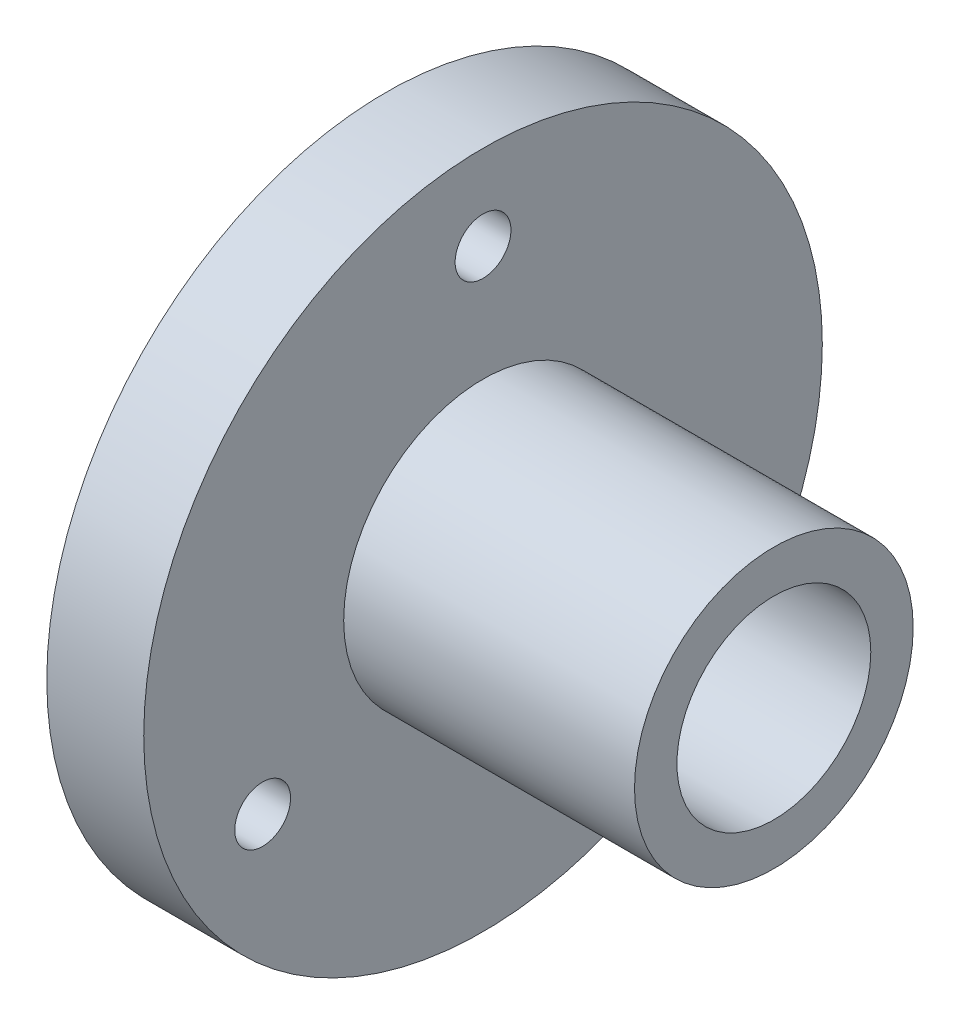
from build123d import *

# Parameters (mm, degrees)
SKETCH_1_R          = 14
SKETCH_1_R_2        = 1.151350939
EXTRUDE_1_DEPTH     = 4
SKETCH_2_R          = 5.75
EXTRUDE_2_DEPTH     = 12
SKETCH_3_R          = 4
CUT_EXTRUDE_1_DEPTH = 16


with BuildPart() as part:
    # ｽｹｯﾁ1 → ﾎﾞｽ - 押し出し1 (new body)
    with BuildSketch(Plane(origin=(0, 0, 0), x_dir=(0, 0, -1), z_dir=(1, 0, 0))):
        Circle(SKETCH_1_R)
        with Locations((0, 10.5)):
            Circle(SKETCH_1_R_2, mode=Mode.SUBTRACT)
        with Locations((9.09326674, -5.25)):
            Circle(SKETCH_1_R_2, mode=Mode.SUBTRACT)
        with Locations((-9.09326674, -5.25)):
            Circle(SKETCH_1_R_2, mode=Mode.SUBTRACT)
    extrude(amount=EXTRUDE_1_DEPTH)

    # ｽｹｯﾁ2 → ﾎﾞｽ - 押し出し2 (add)
    with BuildSketch(Plane(origin=(4, 0, 0), x_dir=(0, 0, -1), z_dir=(1, 0, 0))):
        Circle(SKETCH_2_R)
    extrude(amount=EXTRUDE_2_DEPTH)

    # ｽｹｯﾁ3 → ｶｯﾄ - 押し出し1 (cut)
    with BuildSketch(Plane(origin=(16, 0, 0), x_dir=(0, 0, -1), z_dir=(1, 0, 0))):
        Circle(SKETCH_3_R)
    extrude(amount=-CUT_EXTRUDE_1_DEPTH, mode=Mode.SUBTRACT)


solid = part.part
